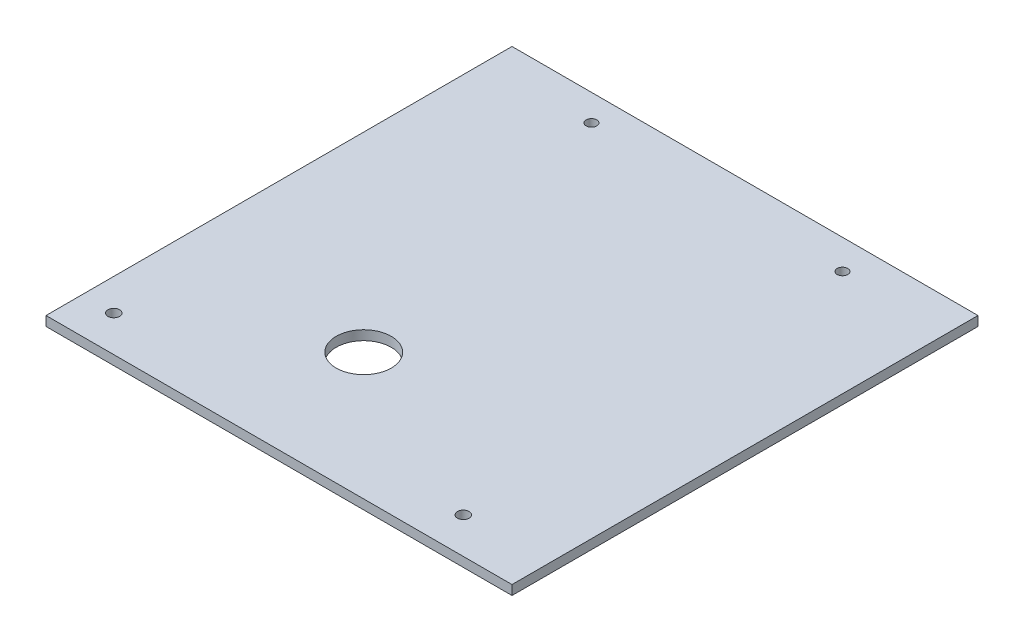
from build123d import *

# Parameters (mm, degrees)
SKETCH1_W           = 220
SKETCH1_H           = 220
BOSS_EXTRUDE1_DEPTH = 4.5
CUT_EXTRUDE1_REACH  = 6.5
SKETCH2_R           = 13
CUT_EXTRUDE2_REACH  = 6.5
SKETCH3_R           = 2.75
CUT_EXTRUDE3_REACH  = 6.5
SKETCH4_R           = 2.5


with BuildPart() as part:
    # Sketch1 → Boss-Extrude1 (new body)
    with BuildSketch(Plane(origin=(0, 0, 0), x_dir=(1, 0, 0), z_dir=(0, 1, 0))):
        Rectangle(SKETCH1_W, SKETCH1_H)
    extrude(amount=BOSS_EXTRUDE1_DEPTH)

    # Sketch2 → Cut-Extrude1 (cut, up to next)
    with BuildSketch(Plane(origin=(0, 4.5, 0), x_dir=(1, 0, 0), z_dir=(0, 1, 0)), mode=Mode.PRIVATE) as cut_extrude1_sk1:
        with Locations((-20, -50)):
            Circle(SKETCH2_R)
    cut_extrude1_tool1 = extrude(cut_extrude1_sk1.sketch, amount=-CUT_EXTRUDE1_REACH, mode=Mode.PRIVATE) & part.part
    add(cut_extrude1_tool1.solids().sort_by_distance((-20, 4.5, 50))[0], mode=Mode.SUBTRACT)

    # Sketch3 → Cut-Extrude2 (cut, up to next)
    with BuildSketch(Plane(origin=(0, 4.5, 0), x_dir=(1, 0, 0), z_dir=(0, 1, 0)), mode=Mode.PRIVATE) as cut_extrude2_sk1:
        with Locations((-95, -93)):
            Circle(SKETCH3_R)
    cut_extrude2_tool1 = extrude(cut_extrude2_sk1.sketch, amount=-CUT_EXTRUDE2_REACH, mode=Mode.PRIVATE) & part.part
    add(cut_extrude2_tool1.solids().sort_by_distance((-95, 4.5, 93))[0], mode=Mode.SUBTRACT)
    # Sketch3 → Cut-Extrude2 (cut, up to next)
    with BuildSketch(Plane(origin=(0, 4.5, 0), x_dir=(1, 0, 0), z_dir=(0, 1, 0)), mode=Mode.PRIVATE) as cut_extrude2_sk2:
        with Locations((70, -93)):
            Circle(SKETCH3_R)
    cut_extrude2_tool2 = extrude(cut_extrude2_sk2.sketch, amount=-CUT_EXTRUDE2_REACH, mode=Mode.PRIVATE) & part.part
    add(cut_extrude2_tool2.solids().sort_by_distance((70, 4.5, 93))[0], mode=Mode.SUBTRACT)

    # Sketch4 → Cut-Extrude3 (cut, up to next)
    with BuildSketch(Plane(origin=(0, 0, 0), x_dir=(-1, 0, 0), z_dir=(0, -1, 0)), mode=Mode.PRIVATE) as cut_extrude3_sk1:
        with Locations((-60, 96)):
            Circle(SKETCH4_R)
    cut_extrude3_tool1 = extrude(cut_extrude3_sk1.sketch, amount=-CUT_EXTRUDE3_REACH, mode=Mode.PRIVATE) & part.part
    add(cut_extrude3_tool1.solids().sort_by_distance((60, 0, -96))[0], mode=Mode.SUBTRACT)
    # Sketch4 → Cut-Extrude3 (cut, up to next)
    with BuildSketch(Plane(origin=(0, 0, 0), x_dir=(-1, 0, 0), z_dir=(0, -1, 0)), mode=Mode.PRIVATE) as cut_extrude3_sk2:
        with Locations((60, 97.5)):
            Circle(SKETCH4_R)
    cut_extrude3_tool2 = extrude(cut_extrude3_sk2.sketch, amount=-CUT_EXTRUDE3_REACH, mode=Mode.PRIVATE) & part.part
    add(cut_extrude3_tool2.solids().sort_by_distance((-60, 0, -97.5))[0], mode=Mode.SUBTRACT)


solid = part.part
